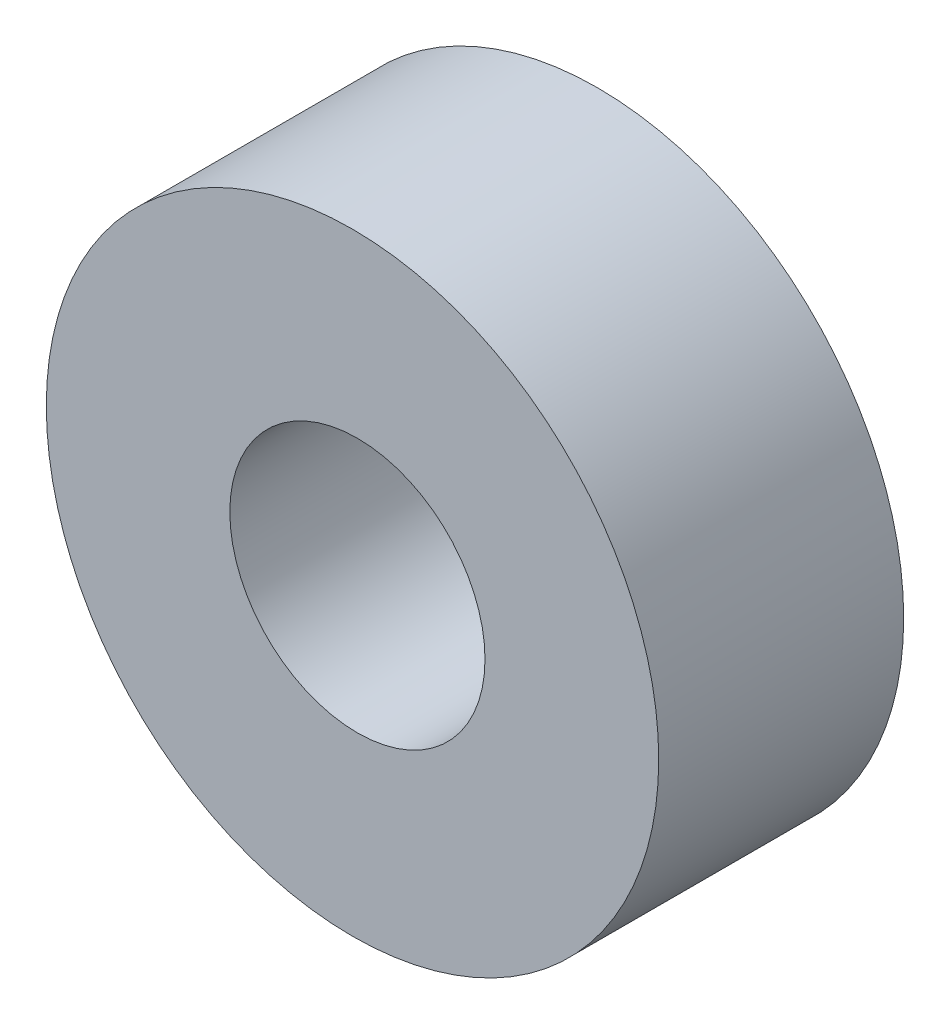
from build123d import *

# Parameters (mm, degrees)
SKETCH1_R           = 30
SKETCH1_R_2         = 12.5
BOSS_EXTRUDE1_DEPTH = 24


with BuildPart() as part:
    # Sketch1 → Boss-Extrude1 (new body)
    with BuildSketch(Plane.XY):
        with Locations((-0.480006827, 0)):
            Circle(SKETCH1_R)
        Circle(SKETCH1_R_2, mode=Mode.SUBTRACT)
    extrude(amount=BOSS_EXTRUDE1_DEPTH)


solid = part.part
